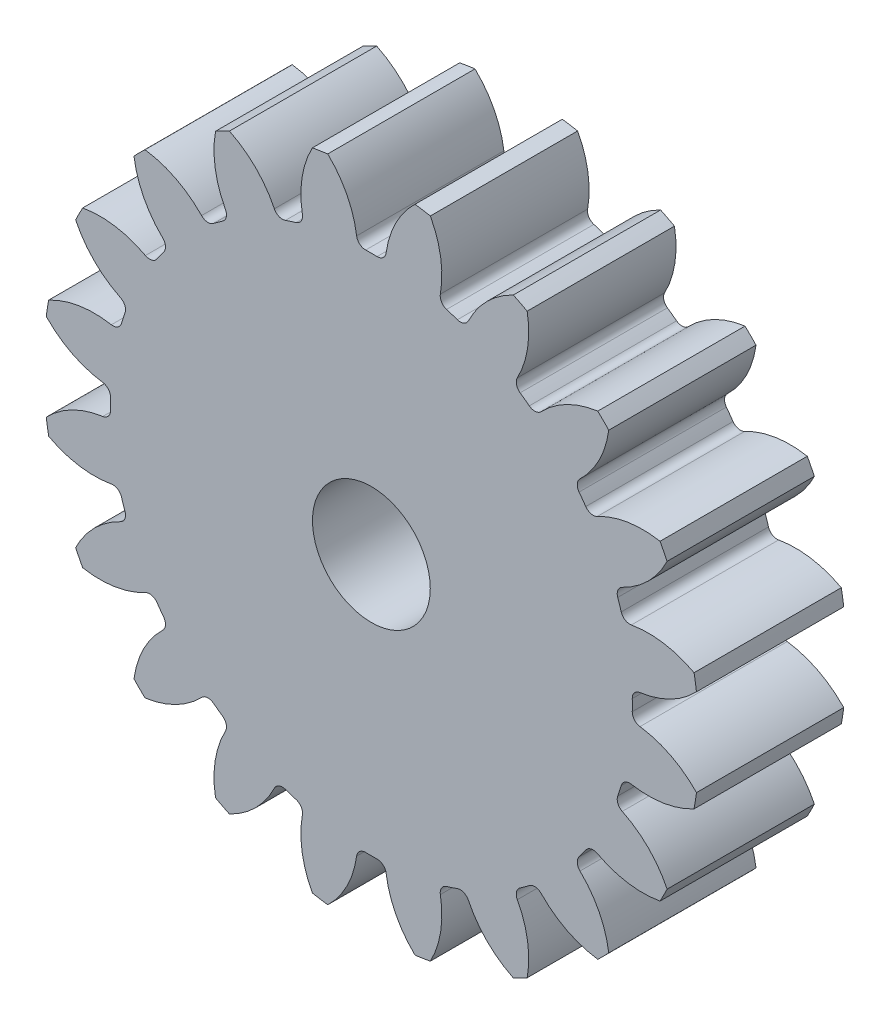
from build123d import *

# Parameters (mm, degrees)
SKETCH1_R                = 22.275
BOSS_EXTRUDE1_DEPTH      = 10
CUT_EXTRUDE1_DEPTH       = 11
FILLET1_R                = 0.6075
CIRPATTERN5_COUNT        = 20
FILLET1_OF_CIRPATTERN5_R = 0.6075
SKETCH3_R                = 4
CUT_EXTRUDE5_DEPTH       = 11.0000001


with BuildPart() as part:
    # Sketch1 → Boss-Extrude1 (new body)
    with BuildSketch(Plane.XY):
        Circle(SKETCH1_R)
    extrude(amount=BOSS_EXTRUDE1_DEPTH)

    # Sketch2 → Cut-Extrude1 (cut, through all)
    with BuildSketch(Plane.XY):
        with BuildLine():
            ThreePointArc((-3.103736564, 22.209174779), (-1.578019513, 20.165106195), (-0.948369682, 17.69335176))
            ThreePointArc((-0.948369682, 17.69335176), (0, 17.71875), (0.948369682, 17.69335176))
            ThreePointArc((0.948369682, 17.69335176), (1.578019513, 20.165106195), (3.103736564, 22.209174779))
            ThreePointArc((3.103736564, 22.209174779), (0, 22.425), (-3.103736564, 22.209174779))
        make_face()
    cut_extrude1 = extrude(amount=CUT_EXTRUDE1_DEPTH, mode=Mode.SUBTRACT)

    # Fillet1
    fillet1_edges = [part.edges().sort_by_distance(p)[0] for p in [
        (0.948369682, 17.69335176, 5),
        (-0.948369682, 17.69335176, 5),
    ]]
    fillet(fillet1_edges, radius=FILLET1_R)

    # CirPattern5: Cut-Extrude1 ×20 about axis
    cirpattern5_axis = Axis((0, 0, 0), (0, 0, 1))
    for i in range(1, CIRPATTERN5_COUNT):
        add(cut_extrude1.rotate(cirpattern5_axis, i * 360 / CIRPATTERN5_COUNT), mode=Mode.SUBTRACT)

    # Fillet1 of CirPattern5
    fillet1_of_cirpattern5_edges = [part.edges().sort_by_distance(p)[0] for p in [
        (-4.565593215, 17.120439835, 5),
        (-6.369499547, 16.534315138, 5),
        (-9.632644039, 14.871659974, 5),
        (-11.167138418, 13.756784549, 5),
        (-13.756784549, 11.167138418, 5),
        (-14.871659974, 9.632644039, 5),
        (-16.534315138, 6.369499547, 5),
        (-17.120439835, 4.565593215, 5),
        (-17.69335176, 0.948369682, 5),
        (-17.69335176, -0.948369682, 5),
        (-17.120439835, -4.565593215, 5),
        (-16.534315138, -6.369499547, 5),
        (-14.871659974, -9.632644039, 5),
        (-13.756784549, -11.167138418, 5),
        (-11.167138418, -13.756784549, 5),
        (-9.632644039, -14.871659974, 5),
        (-6.369499547, -16.534315138, 5),
        (-4.565593215, -17.120439835, 5),
        (-0.948369682, -17.69335176, 5),
        (0.948369682, -17.69335176, 5),
        (4.565593215, -17.120439835, 5),
        (6.369499547, -16.534315138, 5),
        (9.632644039, -14.871659974, 5),
        (11.167138418, -13.756784549, 5),
        (13.756784549, -11.167138418, 5),
        (14.871659974, -9.632644039, 5),
        (16.534315138, -6.369499547, 5),
        (17.120439835, -4.565593215, 5),
        (17.69335176, -0.948369682, 5),
        (17.69335176, 0.948369682, 5),
        (17.120439835, 4.565593215, 5),
        (16.534315138, 6.369499547, 5),
        (14.871659974, 9.632644039, 5),
        (13.756784549, 11.167138418, 5),
        (11.167138418, 13.756784549, 5),
        (9.632644039, 14.871659974, 5),
        (6.369499547, 16.534315138, 5),
        (4.565593215, 17.120439835, 5),
    ]]
    fillet(fillet1_of_cirpattern5_edges, radius=FILLET1_OF_CIRPATTERN5_R)

    # Sketch3 → Cut-Extrude5 (cut, through all)
    with BuildSketch(Plane.XY.offset(10)):
        Circle(SKETCH3_R)
    extrude(amount=-CUT_EXTRUDE5_DEPTH, mode=Mode.SUBTRACT)


solid = part.part
